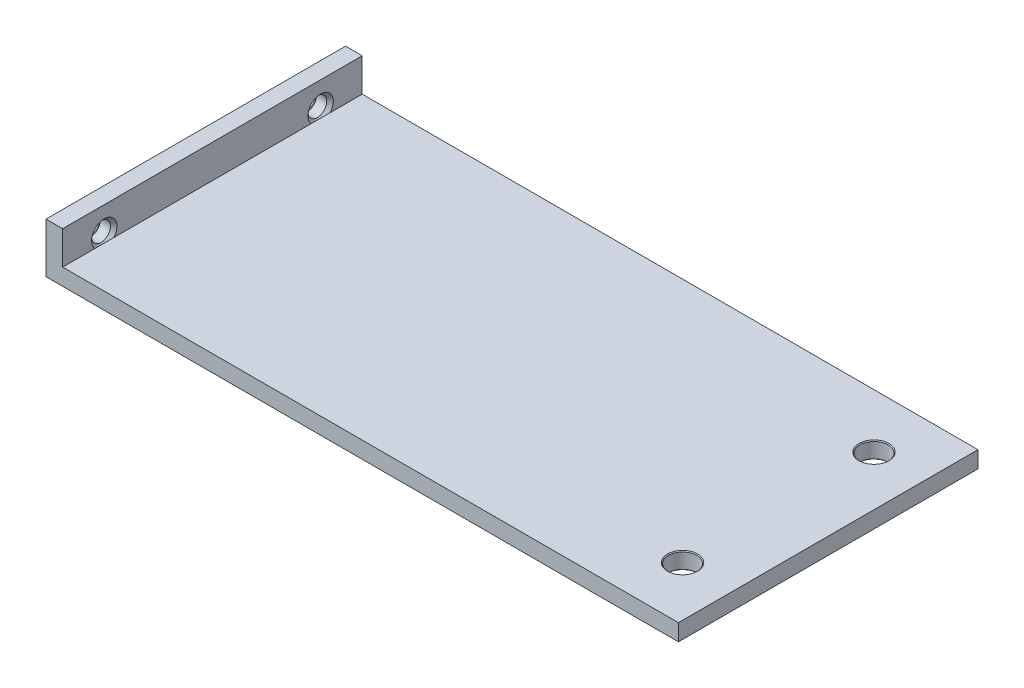
from build123d import *

# Parameters (mm, degrees)
SKETCH_1_W                  = 80
SKETCH_1_H                  = 40
SKETCH_1_W_2                = 76
SKETCH_1_H_2                = 36
EXTRUDE_1_DEPTH             = 36
CUT_EXTRUDE_1_DEPTH         = 37
HOLE_WIZARD_4_40_AT_2_COUNT = 2
HOLE_WIZARD_4_40_AT_2_PITCH = 26
HOLE_WIZARD_M3_AT_2_COUNT   = 2
HOLE_WIZARD_M3_AT_2_PITCH   = 23


with BuildPart() as part:
    # Эскиз1 → Бобышка-Вытянуть1 (new body)
    with BuildSketch(Plane.XY):
        Rectangle(SKETCH_1_W, SKETCH_1_H)
        Rectangle(SKETCH_1_W_2, SKETCH_1_H_2, mode=Mode.SUBTRACT)
    extrude(amount=EXTRUDE_1_DEPTH)

    # Эскиз2 → Вырез-Вытянуть1 (cut, through all)
    with BuildSketch(Plane.XY.offset(36)):
        Polygon((-40, 20), (-40, -14), (-38, -14), (-38, 18), (38, 18), (38, -18), (36, -18), (36, -20), (40, -20), (40, 20), align=None)
    extrude(amount=-CUT_EXTRUDE_1_DEPTH, mode=Mode.SUBTRACT)

    # Эскиз3 → 4-40 (revolve, cut)
    with BuildSketch(Plane(origin=(-40, -17, 5), x_dir=(0, 0, 1), z_dir=(0, 1, 0))):
        Polygon((0, 0), (0, 2), (1.524, 2), (1.1303, 1.6063), (1.1303, 0.3937), (1.524, 0), align=None)
    hole_wizard_4_40 = revolve(axis=Axis((-46.35, -17, 5), (1, 0, 0)), mode=Mode.SUBTRACT)

    # 4-40 at 2: 4-40 ×2
    with Locations(*[(0, 0, i * HOLE_WIZARD_4_40_AT_2_PITCH) for i in range(1, HOLE_WIZARD_4_40_AT_2_COUNT)]):
        add(hole_wizard_4_40, mode=Mode.SUBTRACT)

    # Эскиз5 → Отверстие под  M3 (revolve, cut)
    with BuildSketch(Plane(origin=(30, -18, 6.5), x_dir=(0, 0, 1), z_dir=(1, 0, 0))):
        Polygon((0, 0), (0, 2), (1.8, 2), (1.7, 1.9), (1.7, 0.1), (1.8, 0), align=None)
    hole_wizard_m3 = revolve(axis=Axis((30, -11.65, 6.5), (0, -1, 0)), mode=Mode.SUBTRACT)

    # Отверстие под  M3 at 2: Отверстие под  M3 ×2
    with Locations(*[(0, 0, i * HOLE_WIZARD_M3_AT_2_PITCH) for i in range(1, HOLE_WIZARD_M3_AT_2_COUNT)]):
        add(hole_wizard_m3, mode=Mode.SUBTRACT)


solid = part.part
